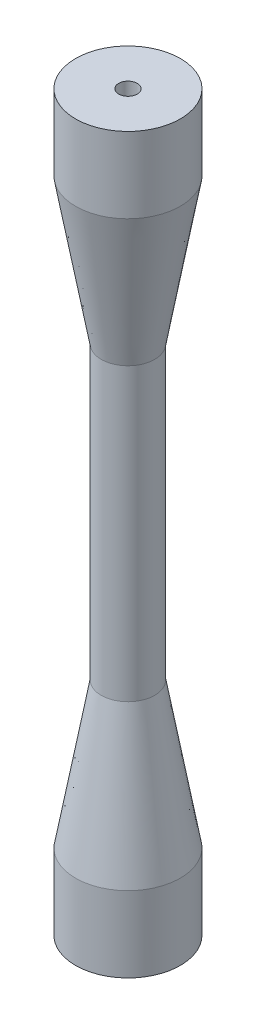
from build123d import *

# Parameters (mm, degrees)
SKETCH1_R           = 9
SKETCH1_R_2         = 1.6
BOSS_EXTRUDE1_DEPTH = 3
BOSS_EXTRUDE2_DEPTH = 10
SKETCH3_R           = 9
BOSS_EXTRUDE3_DEPTH = 25
BOSS_EXTRUDE3_TAPER = 10
SKETCH4_R           = 4.591825482
BOSS_EXTRUDE4_DEPTH = 25


with BuildPart() as part:
    # Sketch1 → Boss-Extrude1 (new body)
    with BuildSketch(Plane(origin=(0, 0, 0), x_dir=(1, 0, 0), z_dir=(0, 1, 0))):
        Circle(SKETCH1_R)
        Circle(SKETCH1_R_2, mode=Mode.SUBTRACT)
    boss_extrude1 = extrude(amount=BOSS_EXTRUDE1_DEPTH)

    # Sketch2 → Boss-Extrude2 (add)
    with BuildSketch(Plane.XZ):
        with BuildLine():
            Line((-7.483314774, 5), (0, 5))
            ThreePointArc((0, 5), (3.535533906, 3.535533906), (5, 0))
            ThreePointArc((5, 0), (3.535533906, -3.535533906), (0, -5))
            Line((0, -5), (-7.483314774, -5))
            ThreePointArc((-7.483314774, -5), (2.61248608, -8.61248608), (9, 0))
            ThreePointArc((9, 0), (2.61248608, 8.61248608), (-7.483314774, 5))
        make_face()
    boss_extrude2 = extrude(amount=BOSS_EXTRUDE2_DEPTH)

    # Sketch3 → Boss-Extrude3 (add)
    with BuildSketch(Plane.XZ.offset(10)):
        Circle(SKETCH3_R)
    boss_extrude3 = extrude(amount=BOSS_EXTRUDE3_DEPTH, taper=BOSS_EXTRUDE3_TAPER)

    # Sketch4 → Boss-Extrude4 (add)
    with BuildSketch(Plane.XZ.offset(35)):
        Circle(SKETCH4_R)
    boss_extrude4 = extrude(amount=BOSS_EXTRUDE4_DEPTH)

    # Mirror2: Boss-Extrude1, Boss-Extrude2, Boss-Extrude3, Boss-Extrude4 across plane
    add(boss_extrude1.mirror(Plane(origin=(0, -60, 0), x_dir=(0, 0, 1), z_dir=(0, -1, 0))))
    add(boss_extrude2.mirror(Plane(origin=(0, -60, 0), x_dir=(0, 0, 1), z_dir=(0, -1, 0))))
    add(boss_extrude3.mirror(Plane(origin=(0, -60, 0), x_dir=(0, 0, 1), z_dir=(0, -1, 0))))
    add(boss_extrude4.mirror(Plane(origin=(0, -60, 0), x_dir=(0, 0, 1), z_dir=(0, -1, 0))))


solid = part.part
